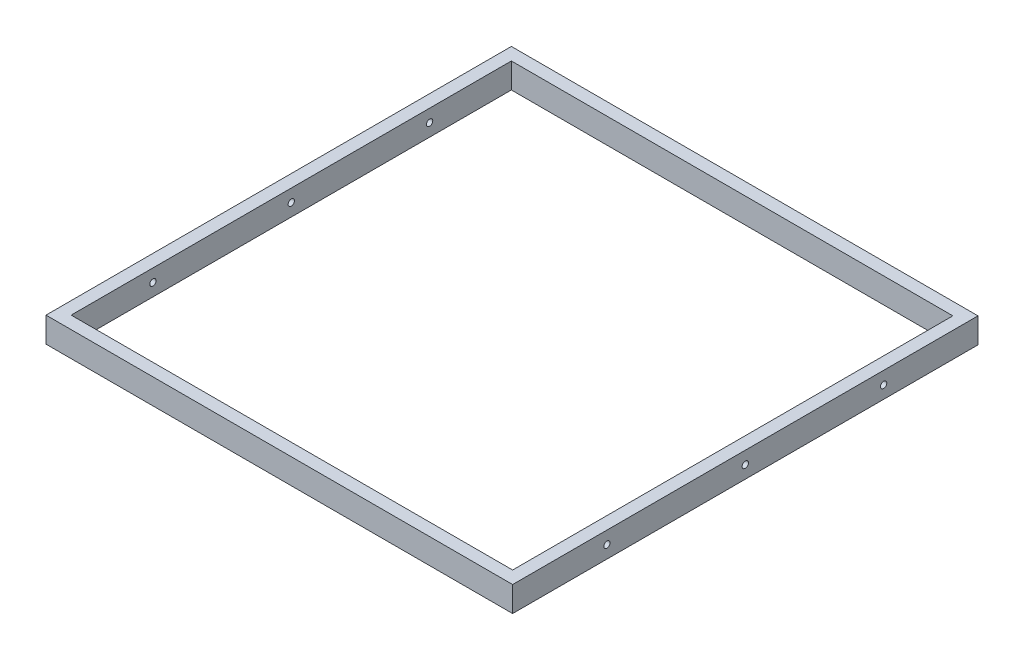
from build123d import *

# Parameters (mm, degrees)
SKETCH1_W           = 371
SKETCH1_H           = 370
SKETCH1_W_2         = 351
SKETCH1_H_2         = 350
BOSS_EXTRUDE1_DEPTH = 20
SKETCH2_R           = 2.5
CUT_EXTRUDE1_DEPTH  = 371


with BuildPart() as part:
    # Sketch1 → Boss-Extrude1 (new body)
    with BuildSketch(Plane(origin=(0, 0, 0), x_dir=(1, 0, 0), z_dir=(0, 1, 0))):
        Rectangle(SKETCH1_W, SKETCH1_H)
        Rectangle(SKETCH1_W_2, SKETCH1_H_2, mode=Mode.SUBTRACT)
    extrude(amount=BOSS_EXTRUDE1_DEPTH)

    # Sketch2 → Cut-Extrude1 (cut)
    with BuildSketch(Plane(origin=(185.5, 0, 0), x_dir=(0, 0, -1), z_dir=(1, 0, 0))):
        with Locations((0, 10)):
            Circle(SKETCH2_R)
        with Locations((110, 10)):
            Circle(SKETCH2_R)
        with Locations((-110, 10)):
            Circle(SKETCH2_R)
    extrude(amount=-CUT_EXTRUDE1_DEPTH, mode=Mode.SUBTRACT)


solid = part.part
